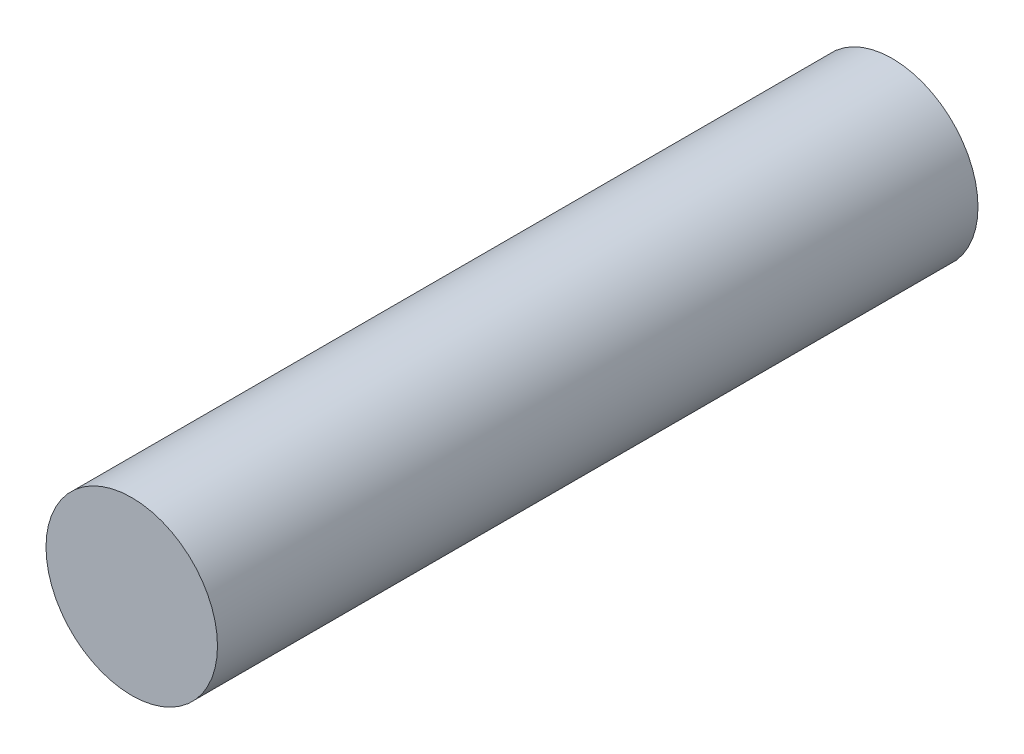
from build123d import *

# Parameters (mm, degrees)
SKETCH1_R           = 9.0195
BOSS_EXTRUDE1_DEPTH = 80


with BuildPart() as part:
    # Sketch1 → Boss-Extrude1 (new body)
    with BuildSketch(Plane.XY):
        Circle(SKETCH1_R)
    extrude(amount=-BOSS_EXTRUDE1_DEPTH)


solid = part.part
